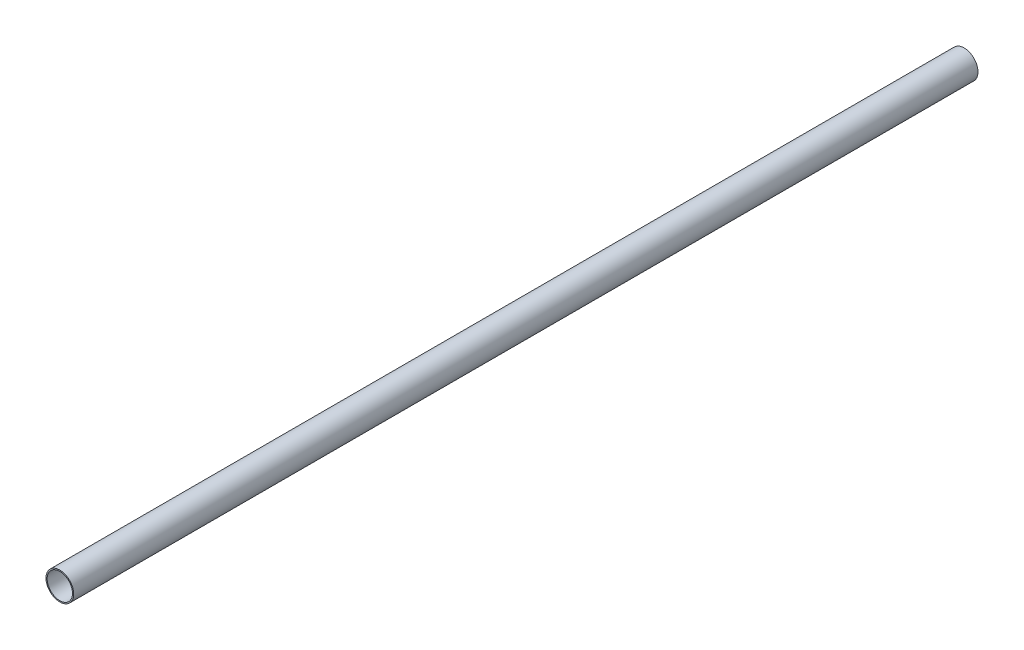
from build123d import *

# Parameters (mm, degrees)
PIPESKETCH_R    = 84.074
PIPESKETCH_R_2  = 76.962
EXTRUSION_DEPTH = 5486.4


with BuildPart() as part:
    # PipeSketch → Extrusion (new body)
    with BuildSketch(Plane.XY):
        Circle(PIPESKETCH_R)
        Circle(PIPESKETCH_R_2, mode=Mode.SUBTRACT)
    extrude(amount=EXTRUSION_DEPTH)


solid = part.part
